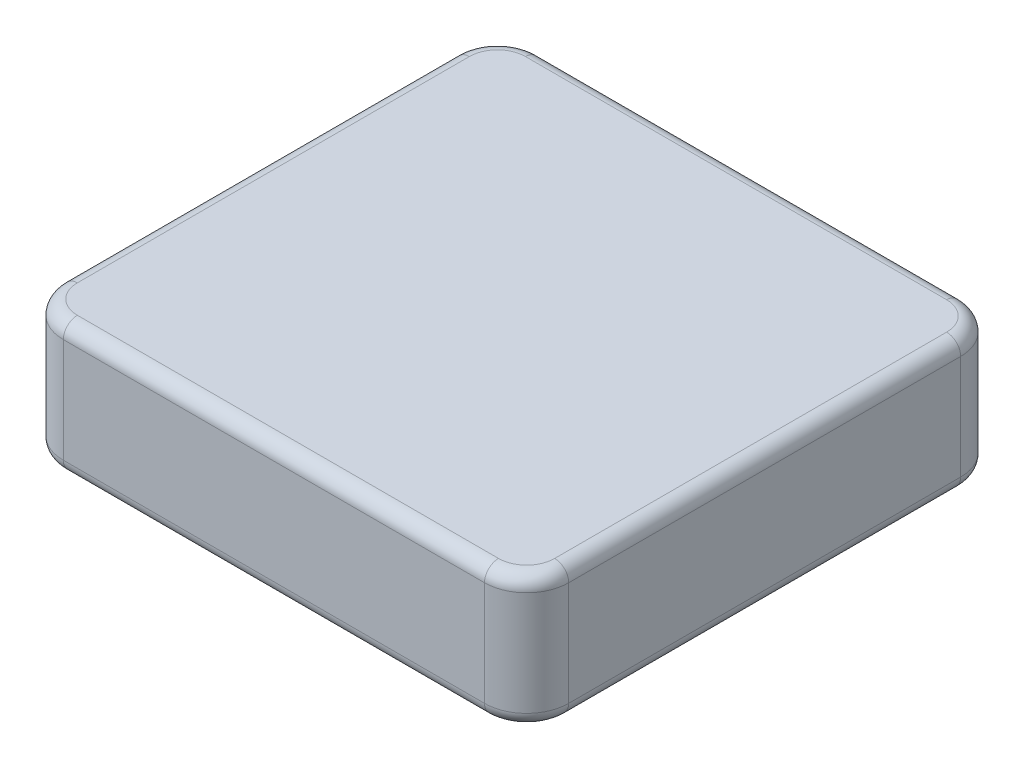
from build123d import *

# Parameters (mm, degrees)
SKETCH1_W           = 114.3
SKETCH1_H           = 107.696
BOSS_EXTRUDE1_DEPTH = 29.972
FILLET1_R           = 9.525
FILLET2_R           = 3.175


with BuildPart() as part:
    # Sketch1 → Boss-Extrude1 (new body)
    with BuildSketch(Plane(origin=(0, 29.972, 0), x_dir=(1, 0, 0), z_dir=(0, 1, 0))):
        Rectangle(SKETCH1_W, SKETCH1_H)
    extrude(amount=-BOSS_EXTRUDE1_DEPTH)

    # Fillet1
    fillet1_edges = [part.edges().sort_by_distance(p)[0] for p in [
        (-57.15, 14.986, 53.848),
        (-57.15, 14.986, -53.848),
        (57.15, 14.986, -53.848),
        (57.15, 14.986, 53.848),
    ]]
    fillet(fillet1_edges, radius=FILLET1_R)

    # Fillet2
    fillet2_edges = [part.edges().sort_by_distance(p)[0] for p in [
        (0, 29.972, -53.848),
        (0, 0, -53.848),
        (0, 29.972, 53.848),
        (57.15, 29.972, 0),
        (-57.15, 29.972, 0),
        (54.360192091, 29.972, 51.058192091),
        (-54.360192091, 29.972, 51.058192091),
        (54.360192091, 29.972, -51.058192091),
        (-54.360192091, 29.972, -51.058192091),
        (-57.15, 0, 0),
        (0, 0, 53.848),
        (57.15, 0, 0),
        (54.360192091, 0, 51.058192091),
        (-54.360192091, 0, 51.058192091),
        (54.360192091, 0, -51.058192091),
        (-54.360192091, 0, -51.058192091),
    ]]
    fillet(fillet2_edges, radius=FILLET2_R)


solid = part.part
